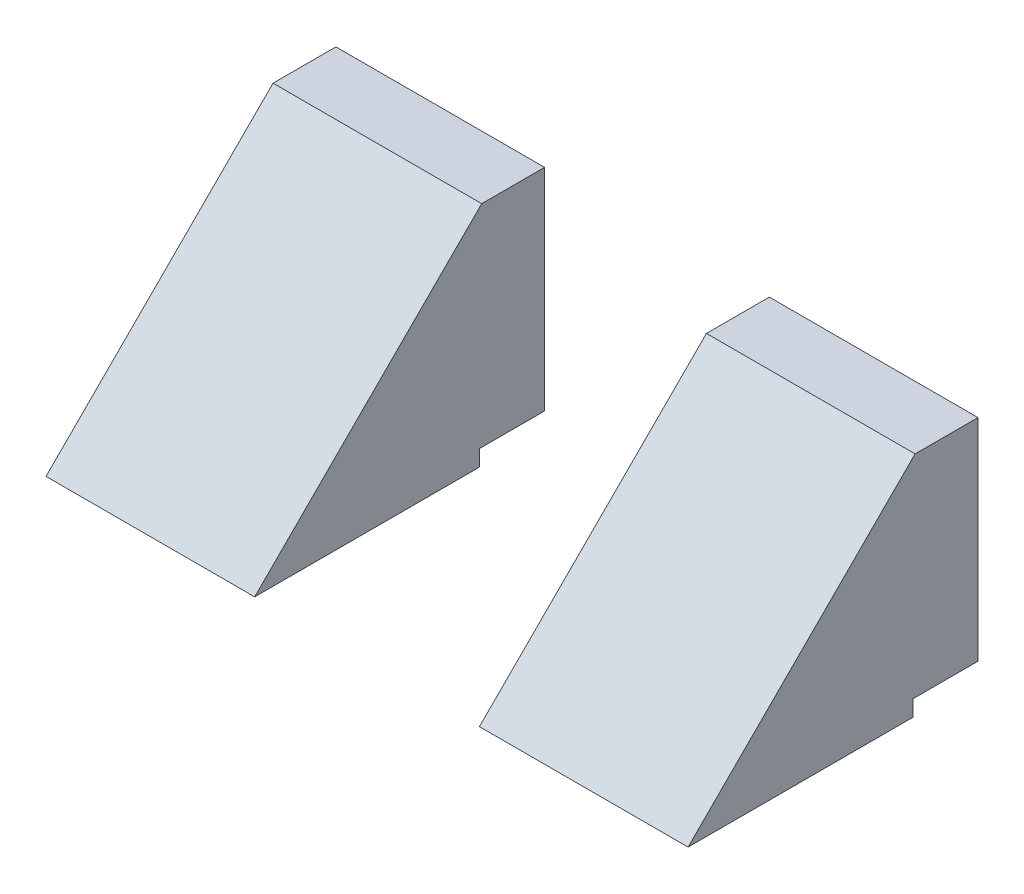
from build123d import *

# Parameters (mm, degrees)
BOSS_EXTRUDE1_DEPTH = 200
SKETCH2_W           = 70
SKETCH2_H           = 90.3
CUT_EXTRUDE1_DEPTH  = 238


with BuildPart() as part:
    # Sketch1 → Boss-Extrude1 (new body)
    with BuildSketch(Plane(origin=(0, 0, 0), x_dir=(0, 0, -1), z_dir=(1, 0, 0))):
        Polygon((-1.988508557, 39.959489294), (-21.574333037, 39.959489294), (-92.288508557, -30.754686227), (-22.288508557, -30.754686227), (-22.288508557, -25.754686227), (-1.988508557, -25.754686227), align=None)
    extrude(amount=BOSS_EXTRUDE1_DEPTH)

    # Sketch2 → Cut-Extrude1 (cut)
    with BuildSketch(Plane(origin=(0, 39.959489294, 0), x_dir=(1, 0, 0), z_dir=(0, 1, 0))):
        with Locations((100, -47.138508557)):
            Rectangle(SKETCH2_W, SKETCH2_H)
    extrude(amount=-CUT_EXTRUDE1_DEPTH, mode=Mode.SUBTRACT)


solid = part.part
